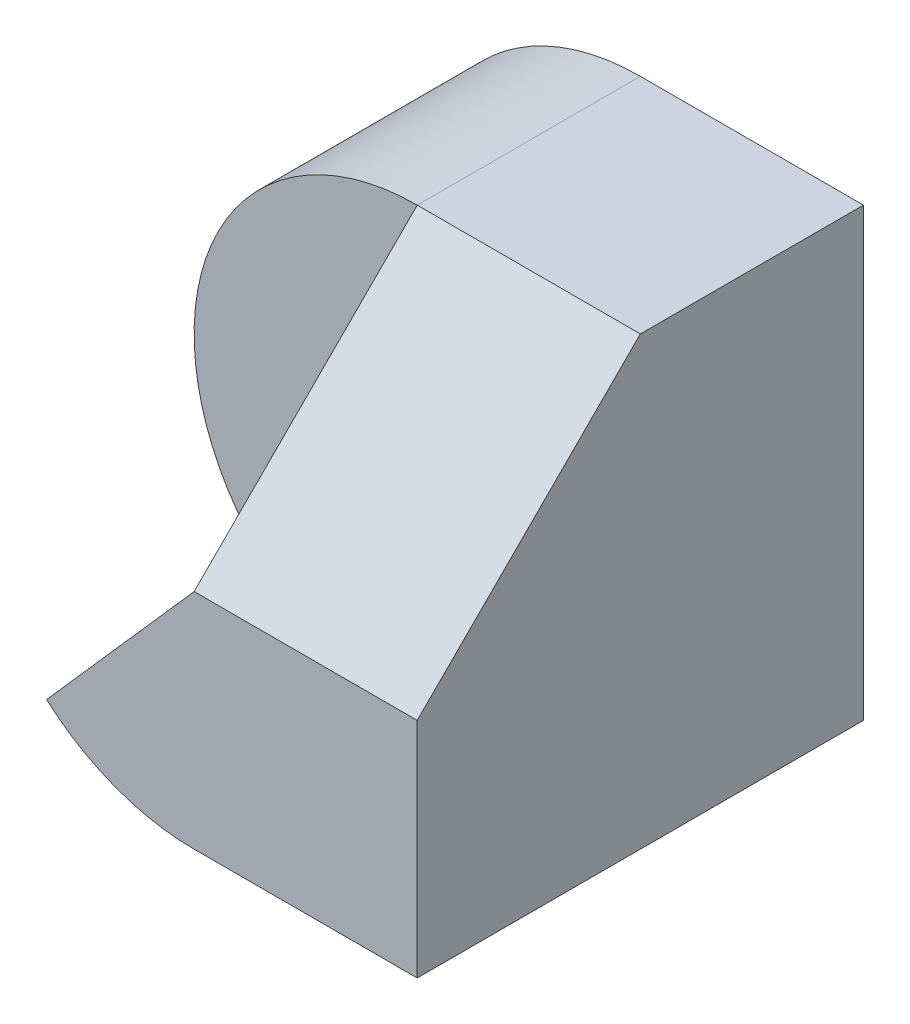
from build123d import *

# Parameters (mm, degrees)
SKETCH1_W           = 40
SKETCH1_H           = 40
BOSS_EXTRUDE1_DEPTH = 40
CUT_EXTRUDE1_DEPTH  = 40
SKETCH3_W           = 5
SKETCH3_H           = 20
CUT_EXTRUDE3_DEPTH  = 40
CUT_EXTRUDE4_DEPTH  = 40
SKETCH5_W           = 20
SKETCH5_H           = 20
CUT_EXTRUDE6_DEPTH  = 20
CUT_EXTRUDE8_DEPTH  = 20
BOSS_EXTRUDE3_DEPTH = 20


with BuildPart() as part:
    # Sketch1 → Boss-Extrude1 (new body)
    with BuildSketch(Plane.XY):
        with Locations((20, 20)):
            Rectangle(SKETCH1_W, SKETCH1_H)
    extrude(amount=BOSS_EXTRUDE1_DEPTH)

    # Sketch2 → Cut-Extrude1 (cut)
    with BuildSketch(Plane.XY.offset(40)):
        with BuildLine():
            ThreePointArc((0, 20), (5.857864376, 34.142135624), (20, 40))
            Line((20, 40), (0, 40))
            Line((0, 40), (0, 20))
        make_face()
        with BuildLine():
            ThreePointArc((20, 0), (5.857864376, 5.857864376), (0, 20))
            Line((0, 20), (0, 0))
            Line((0, 0), (20, 0))
        make_face()
    extrude(amount=-CUT_EXTRUDE1_DEPTH, mode=Mode.SUBTRACT)

    # Sketch3 → Cut-Extrude3 (cut)
    with BuildSketch(Plane(origin=(0, 40, 0), x_dir=(1, 0, 0), z_dir=(0, 1, 0))):
        with Locations((2.5, -30)):
            Rectangle(SKETCH3_W, SKETCH3_H)
    extrude(amount=-CUT_EXTRUDE3_DEPTH, mode=Mode.SUBTRACT)

    # Sketch4 → Cut-Extrude4 (cut)
    with BuildSketch(Plane(origin=(0, 0, 0), x_dir=(0, 0, -1), z_dir=(1, 0, 0))):
        Polygon((-20, 40), (-40, 20), (-40, 40), align=None)
    extrude(amount=CUT_EXTRUDE4_DEPTH, mode=Mode.SUBTRACT)

    # Sketch5 → Cut-Extrude6 (cut)
    with BuildSketch(Plane.XY.offset(40)):
        with Locations((30, 30)):
            Rectangle(SKETCH5_W, SKETCH5_H)
    extrude(amount=-CUT_EXTRUDE6_DEPTH, mode=Mode.SUBTRACT)

    # Sketch6 → Cut-Extrude8 (cut)
    with BuildSketch(Plane.XY.offset(40)):
        with BuildLine():
            Line((6.771243445, 5), (20, 20))
            Line((20, 20), (5, 20))
            Line((5, 20), (5, 6.771243445))
            ThreePointArc((5, 6.771243445), (5.857864376, 5.857864376), (6.771243445, 5))
        make_face()
        with BuildLine():
            Line((5, 20), (20, 20))
            Line((20, 20), (20, 40))
            ThreePointArc((20, 40), (1.771243445, 28.228756555), (5, 6.771243445))
            Line((5, 6.771243445), (5, 20))
        make_face()
    extrude(amount=-CUT_EXTRUDE8_DEPTH, mode=Mode.SUBTRACT)

    # Sketch7 → Boss-Extrude3 (add)
    with BuildSketch(Plane(origin=(40, 0, 0), x_dir=(0, 0, -1), z_dir=(1, 0, 0))):
        Polygon((-20, 40), (-40, 20), (-20, 20), align=None)
    extrude(amount=-BOSS_EXTRUDE3_DEPTH)


solid = part.part
